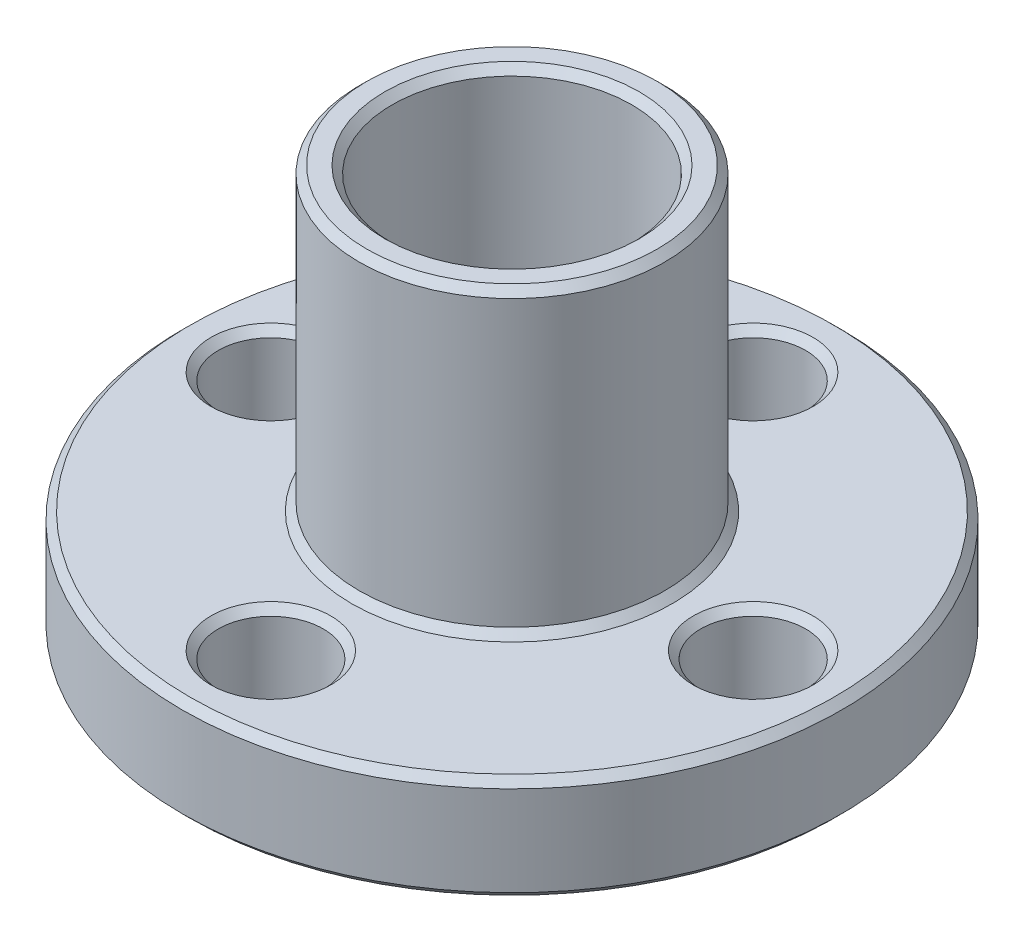
from build123d import *

# Parameters (mm, degrees)
SKETCH1_R           = 11
SKETCH1_R_2         = 1.75
SKETCH1_R_3         = 4
BOSS_EXTRUDE1_DEPTH = 3.5
SKETCH1_3_R         = 5.1
SKETCH1_3_R_2       = 4
BOSS_EXTRUDE2_DEPTH = 13.5
CHAMFER1_SIZE       = 0.25


with BuildPart() as part:
    # Sketch1 → Boss-Extrude1 (new body)
    with BuildSketch(Plane(origin=(0, 0, 0), x_dir=(1, 0, 0), z_dir=(0, 1, 0))):
        Circle(SKETCH1_R)
        with Locations((-8.05, 0)):
            Circle(SKETCH1_R_2, mode=Mode.SUBTRACT)
        with Locations((0, -8.05)):
            Circle(SKETCH1_R_2, mode=Mode.SUBTRACT)
        with Locations((8.05, 0)):
            Circle(SKETCH1_R_2, mode=Mode.SUBTRACT)
        with Locations((0, 8.05)):
            Circle(SKETCH1_R_2, mode=Mode.SUBTRACT)
        Circle(SKETCH1_R_3, mode=Mode.SUBTRACT)
    extrude(amount=BOSS_EXTRUDE1_DEPTH)

    # Sketch1_3 → Boss-Extrude2 (add)
    with BuildSketch(Plane(origin=(0, 0, 0), x_dir=(1, 0, 0), z_dir=(0, 1, 0))):
        Circle(SKETCH1_3_R)
        Circle(SKETCH1_3_R_2, mode=Mode.SUBTRACT)
    extrude(amount=BOSS_EXTRUDE2_DEPTH)

    # Chamfer1
    chamfer1_edges = [part.edges().sort_by_distance(p)[0] for p in [
        (6.3, 3.5, 0),
        (6.3, 0, 0),
        (-1.75, 3.5, -8.05),
        (-1.75, 0, -8.05),
        (-1.75, 0, 8.05),
        (-1.75, 3.5, 8.05),
        (-9.8, 0, 0),
        (-9.8, 3.5, 0),
        (-4, 13.5, 0),
        (-5.1, 13.5, 0),
        (-5.1, 3.5, 0),
        (-11, 3.5, 0),
        (-11, 0, 0),
        (-4, 0, 0),
    ]]
    chamfer(chamfer1_edges, length=CHAMFER1_SIZE)


solid = part.part
